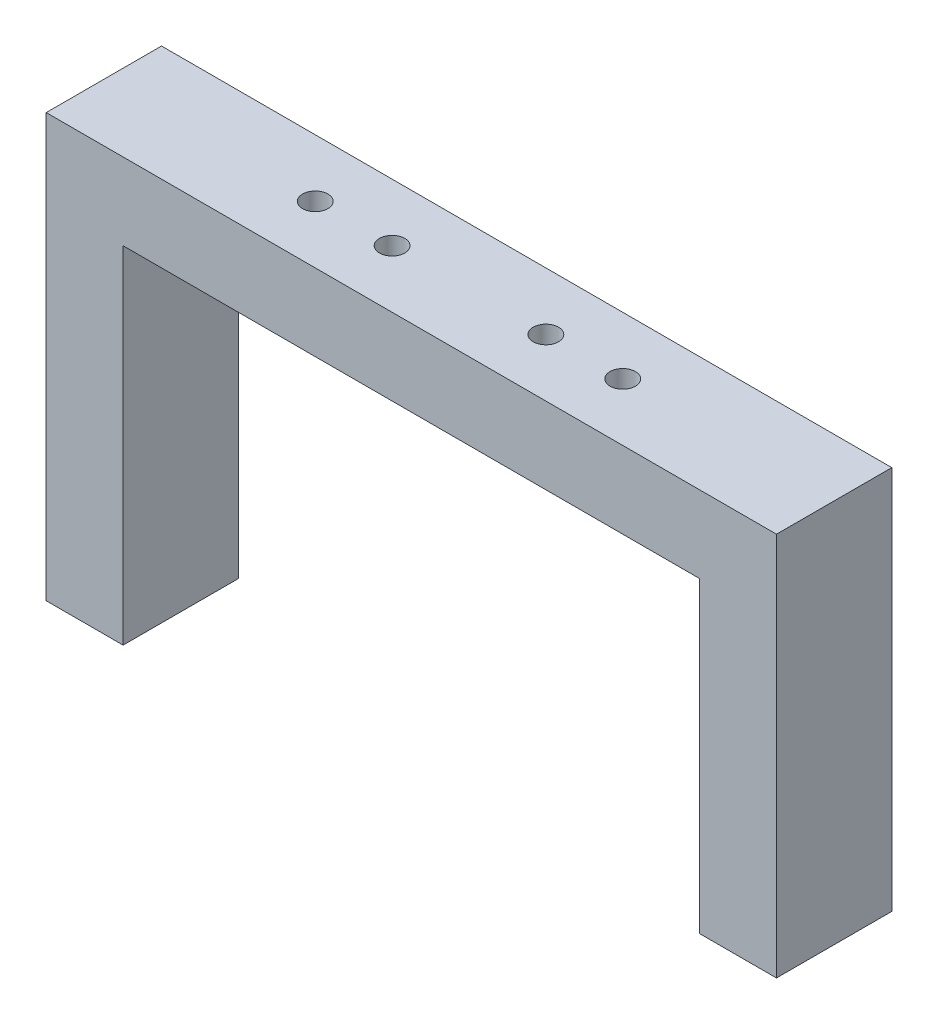
from build123d import *

# Parameters (mm, degrees)
BOSS_EXTRUDE1_DEPTH = 7.5
CUT_EXTRUDE1_REACH  = 57
SKETCH2_R           = 1.65


with BuildPart() as part:
    # Sketch1 → Boss-Extrude1 (new body, symmetric)
    with BuildSketch(Plane.XY):
        Polygon((-37.5, 0), (37.5, 0), (37.5, -40), (47.5, -40), (47.5, 10), (-47.5, 10), (-47.5, -45), (-37.5, -45), align=None)
    extrude(amount=BOSS_EXTRUDE1_DEPTH, both=True)

    # Sketch2 → Cut-Extrude1 (cut, up to next)
    with BuildSketch(Plane(origin=(0, 10, 0), x_dir=(1, 0, 0), z_dir=(0, 1, 0)), mode=Mode.PRIVATE) as cut_extrude1_sk1:
        with Locations((-10, 0)):
            Circle(SKETCH2_R)
    cut_extrude1_tool1 = extrude(cut_extrude1_sk1.sketch, amount=-CUT_EXTRUDE1_REACH, mode=Mode.PRIVATE) & part.part
    add(cut_extrude1_tool1.solids().sort_by_distance((-10, 10, 0))[0], mode=Mode.SUBTRACT)
    # Sketch2 → Cut-Extrude1 (cut, up to next)
    with BuildSketch(Plane(origin=(0, 10, 0), x_dir=(1, 0, 0), z_dir=(0, 1, 0)), mode=Mode.PRIVATE) as cut_extrude1_sk2:
        with Locations((10, 0)):
            Circle(SKETCH2_R)
    cut_extrude1_tool2 = extrude(cut_extrude1_sk2.sketch, amount=-CUT_EXTRUDE1_REACH, mode=Mode.PRIVATE) & part.part
    add(cut_extrude1_tool2.solids().sort_by_distance((10, 10, 0))[0], mode=Mode.SUBTRACT)
    # Sketch2 → Cut-Extrude1 (cut, up to next)
    with BuildSketch(Plane(origin=(0, 10, 0), x_dir=(1, 0, 0), z_dir=(0, 1, 0)), mode=Mode.PRIVATE) as cut_extrude1_sk3:
        with Locations((20, 0)):
            Circle(SKETCH2_R)
    cut_extrude1_tool3 = extrude(cut_extrude1_sk3.sketch, amount=-CUT_EXTRUDE1_REACH, mode=Mode.PRIVATE) & part.part
    add(cut_extrude1_tool3.solids().sort_by_distance((20, 10, 0))[0], mode=Mode.SUBTRACT)
    # Sketch2 → Cut-Extrude1 (cut, up to next)
    with BuildSketch(Plane(origin=(0, 10, 0), x_dir=(1, 0, 0), z_dir=(0, 1, 0)), mode=Mode.PRIVATE) as cut_extrude1_sk4:
        with Locations((-20, 0)):
            Circle(SKETCH2_R)
    cut_extrude1_tool4 = extrude(cut_extrude1_sk4.sketch, amount=-CUT_EXTRUDE1_REACH, mode=Mode.PRIVATE) & part.part
    add(cut_extrude1_tool4.solids().sort_by_distance((-20, 10, 0))[0], mode=Mode.SUBTRACT)


solid = part.part
